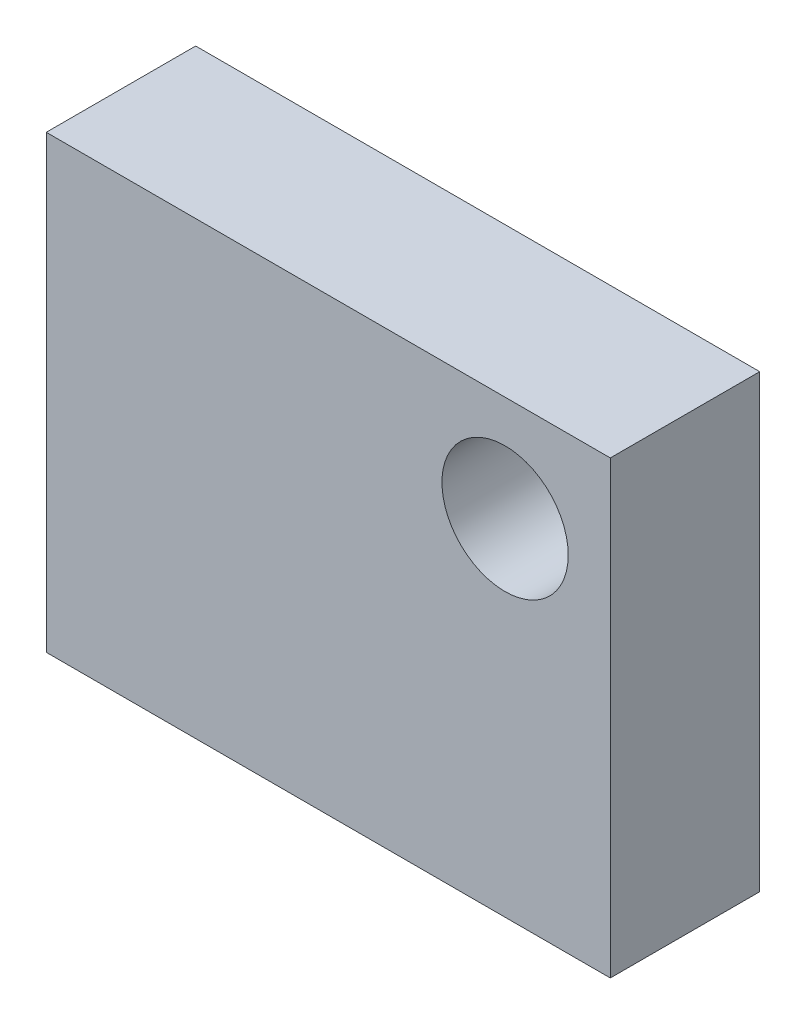
from build123d import *

# Parameters (mm, degrees)
SKETCH1_W           = 13.4
SKETCH1_H           = 10.7
BOSS_EXTRUDE1_DEPTH = 3.55
SKETCH2_R           = 1.5
CUT_EXTRUDE1_DEPTH  = 3.55


with BuildPart() as part:
    # Sketch1 → Boss-Extrude1 (new body)
    with BuildSketch(Plane.XY):
        Rectangle(SKETCH1_W, SKETCH1_H)
    extrude(amount=BOSS_EXTRUDE1_DEPTH)

    # Sketch2 → Cut-Extrude1 (cut)
    with BuildSketch(Plane.XY.offset(3.55)):
        with Locations((4.2, 2.85)):
            Circle(SKETCH2_R)
    extrude(amount=-CUT_EXTRUDE1_DEPTH, mode=Mode.SUBTRACT)


solid = part.part
